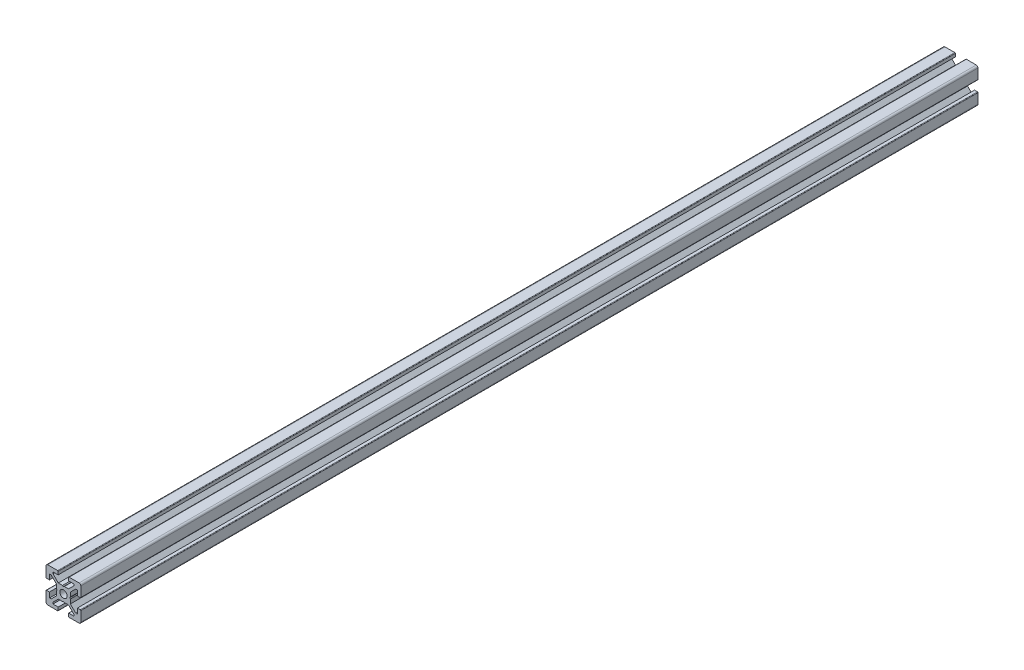
from build123d import *

# Parameters (mm, degrees)
BOSS_EXTRUDE1_DEPTH = 515
SKETCH2_W           = 515
SKETCH2_H           = 2.1


with BuildPart() as part:
    # Sketch1 → Boss-Extrude1 (new body)
    with BuildSketch(Plane.XY):
        with BuildLine():
            Line((-10, 9), (-10, 3.29999995))
            ThreePointArc((-10, 3.29999995), (-9.912132049, 3.087867916), (-9.7, 3))
            Line((-9.7, 3), (-8, 3))
            Line((-8, 3), (-8, 6))
            Line((-8, 6), (-7.060677, 6))
            Line((-7.060677, 6), (-4, 2.93932965))
            Line((-4, 2.93932965), (-4, 0.519615242))
            Line((-4, 0.519615242), (-3.699996283, -6.437e-06))
            Line((-3.699996283, -6.437e-06), (-4, -0.519628117))
            Line((-4, -0.519628117), (-4, -2.93933725))
            Line((-4, -2.93933725), (-7.0606695, -6))
            Line((-7.0606695, -6), (-8, -6))
            Line((-8, -6), (-8, -3))
            Line((-8, -3), (-9.7, -3))
            ThreePointArc((-9.7, -3), (-9.912132049, -3.087867916), (-10, -3.29999995))
            Line((-10, -3.29999995), (-10, -9))
            ThreePointArc((-10, -9), (-9.707106781, -9.707106781), (-9, -10))
            Line((-9, -10), (-3.29999995, -10))
            ThreePointArc((-3.29999995, -10), (-3.087867916, -9.912132049), (-3, -9.7))
            Line((-3, -9.7), (-3, -8))
            Line((-3, -8), (-6, -8))
            Line((-6, -8), (-6, -7.0606515))
            Line((-6, -7.0606515), (-2.9393489, -4))
            Line((-2.9393489, -4), (-0.519615242, -4))
            Line((-0.519615242, -4), (6.437e-06, -3.699996283))
            Line((6.437e-06, -3.699996283), (0.519628117, -4))
            Line((0.519628117, -4), (2.9393227, -4))
            Line((2.9393227, -4), (6, -7.060677))
            Line((6, -7.060677), (6, -8))
            Line((6, -8), (3, -8))
            Line((3, -8), (3, -9.7))
            ThreePointArc((3, -9.7), (3.087867916, -9.912132049), (3.29999995, -10))
            Line((3.29999995, -10), (9, -10))
            ThreePointArc((9, -10), (9.707106781, -9.707106781), (10, -9))
            Line((10, -9), (10, -3.29999995))
            ThreePointArc((10, -3.29999995), (9.912132049, -3.087867916), (9.7, -3))
            Line((9.7, -3), (8, -3))
            Line((8, -3), (8, -6))
            Line((8, -6), (7.0606435, -6))
            Line((7.0606435, -6), (4, -2.9393482))
            Line((4, -2.9393482), (4, -0.519615242))
            Line((4, -0.519615242), (3.699996283, 6.437e-06))
            Line((3.699996283, 6.437e-06), (4, 0.519628117))
            Line((4, 0.519628117), (4, 2.9393401))
            Line((4, 2.9393401), (7.060651, 6))
            Line((7.060651, 6), (8, 6))
            Line((8, 6), (8, 3))
            Line((8, 3), (9.7, 3))
            ThreePointArc((9.7, 3), (9.912132049, 3.087867916), (10, 3.29999995))
            Line((10, 3.29999995), (10, 9))
            ThreePointArc((10, 9), (9.707106781, 9.707106781), (9, 10))
            Line((9, 10), (3.29999995, 10))
            ThreePointArc((3.29999995, 10), (3.087867916, 9.912132049), (3, 9.7))
            Line((3, 9.7), (3, 8))
            Line((3, 8), (6, 8))
            Line((6, 8), (6, 7.060669))
            Line((6, 7.060669), (2.9393308, 4))
            Line((2.9393308, 4), (0.519615242, 4))
            Line((0.519615242, 4), (-6.437e-06, 3.699996283))
            Line((-6.437e-06, 3.699996283), (-0.519628117, 4))
            Line((-0.519628117, 4), (-2.93935655, 4))
            Line((-2.93935655, 4), (-6, 7.0606435))
            Line((-6, 7.0606435), (-6, 8))
            Line((-6, 8), (-3, 8))
            Line((-3, 8), (-3, 9.7))
            ThreePointArc((-3, 9.7), (-3.087867966, 9.912132034), (-3.3, 10))
            Line((-3.3, 10), (-9, 10))
            ThreePointArc((-9, 10), (-9.707106781, 9.707106781), (-10, 9))
        make_face()
    extrude(amount=-BOSS_EXTRUDE1_DEPTH)

    # Sketch2 → Cut-Revolve1 (revolve, cut)
    with BuildSketch(Plane(origin=(0, 0, 0), x_dir=(0, 0, -1), z_dir=(1, 0, 0))):
        with Locations((257.5, 1.05)):
            Rectangle(SKETCH2_W, SKETCH2_H)
    revolve(axis=Axis((0, 0, -515), (0, 0, 1)), mode=Mode.SUBTRACT)


solid = part.part
